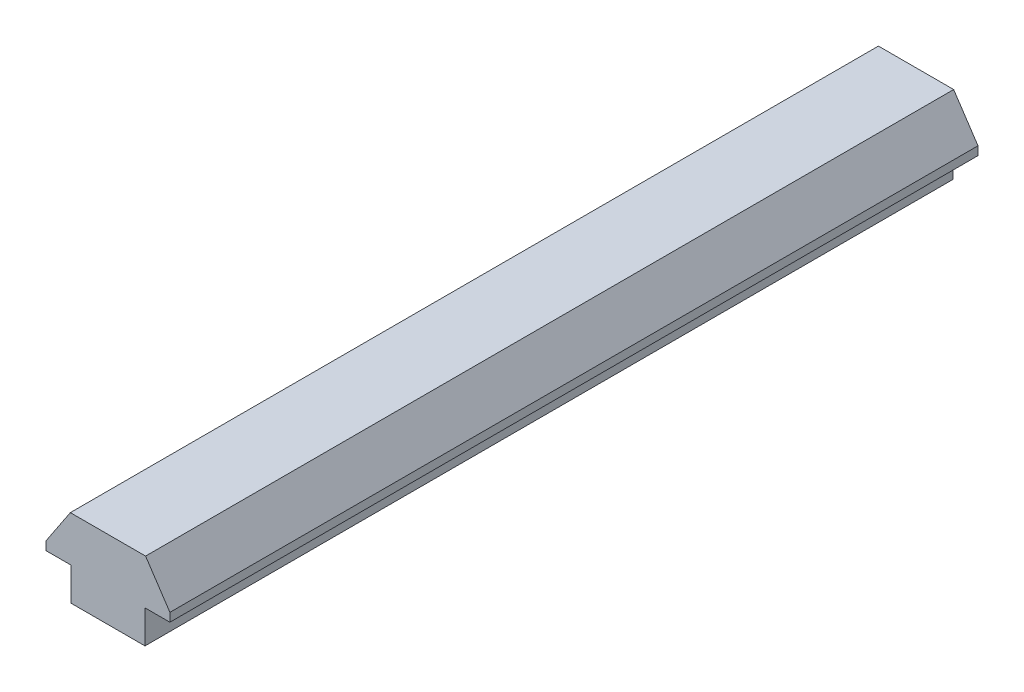
from build123d import *

# Parameters (mm, degrees)
SKETCH1_W           = 5.5
SKETCH1_H           = 2.45
BOSS_EXTRUDE1_DEPTH = 60
BOSS_EXTRUDE2_DEPTH = 60


with BuildPart() as part:
    # Sketch1 → Boss-Extrude1 (new body)
    with BuildSketch(Plane.XY):
        with Locations((0, 1.225)):
            Rectangle(SKETCH1_W, SKETCH1_H)
    extrude(amount=BOSS_EXTRUDE1_DEPTH)

    # Sketch2 → Boss-Extrude2 (add)
    with BuildSketch(Plane.XY):
        Polygon((-4.6, 2.45), (4.6, 2.45), (4.6, 3.085), (2.794, 5.8), (-2.794, 5.8), (-4.6, 3.085), align=None)
    extrude(amount=BOSS_EXTRUDE2_DEPTH)


solid = part.part
